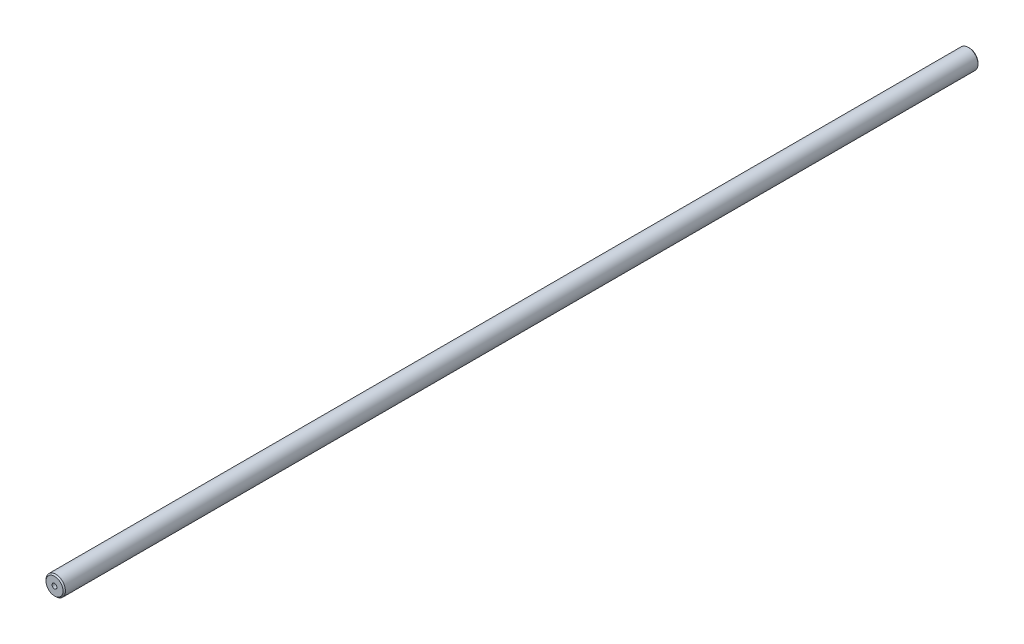
from build123d import *

# Parameters (mm, degrees)
SKETCH1_R           = 4
BOSS_EXTRUDE1_DEPTH = 376
SKETCH2_R           = 1
CUT_EXTRUDE1_DEPTH  = 10
CHAMFER1_SIZE       = 0.5


with BuildPart() as part:
    # Sketch1 → Boss-Extrude1 (new body)
    with BuildSketch(Plane.XY):
        Circle(SKETCH1_R)
    extrude(amount=BOSS_EXTRUDE1_DEPTH)

    # Sketch2 → Cut-Extrude1 (cut)
    with BuildSketch(Plane.XY.offset(376)):
        Circle(SKETCH2_R)
    extrude(amount=-CUT_EXTRUDE1_DEPTH, mode=Mode.SUBTRACT)

    # Chamfer1
    chamfer1_edges = [part.edges().sort_by_distance(p)[0] for p in [
        (-4, 0, 0),
        (-4, 0, 376),
    ]]
    chamfer(chamfer1_edges, length=CHAMFER1_SIZE)


solid = part.part
